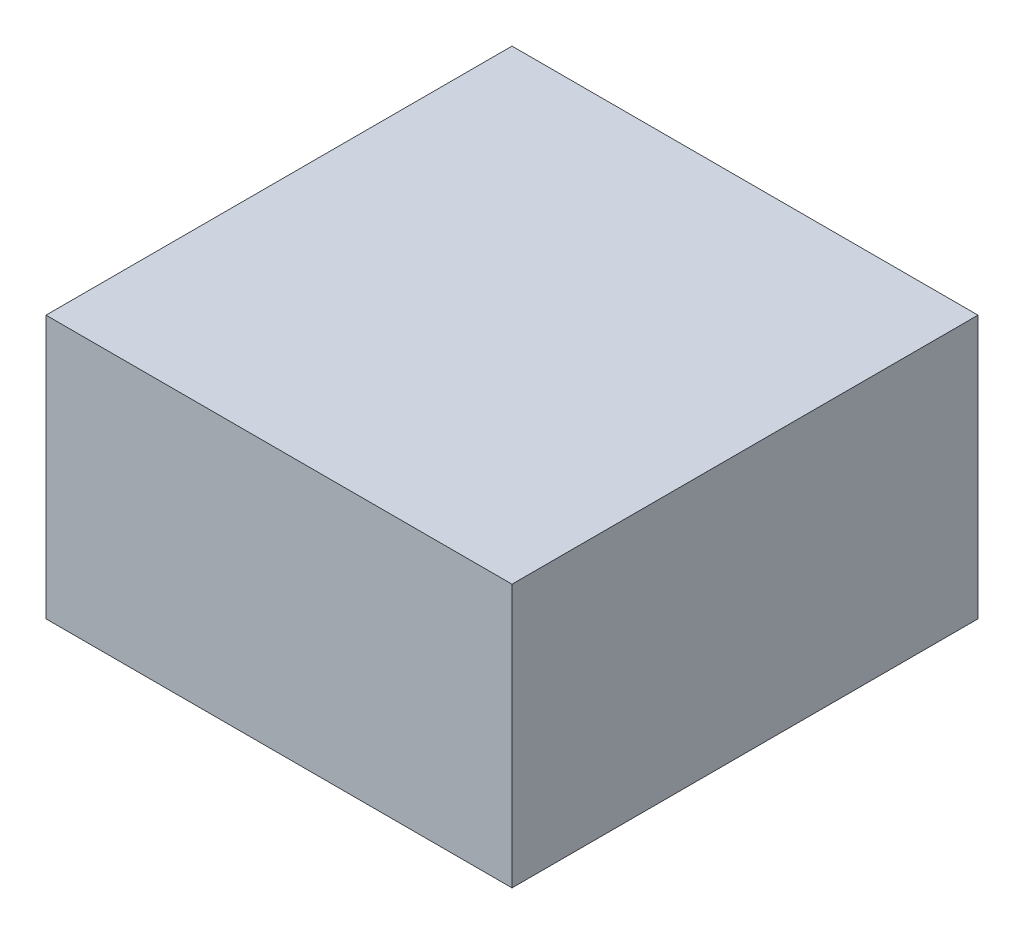
from build123d import *

# Parameters (mm, degrees)
SKETCH1_W           = 45
SKETCH1_H           = 45
BOSS_EXTRUDE1_DEPTH = 25.4


with BuildPart() as part:
    # Sketch1 → Boss-Extrude1 (new body)
    with BuildSketch(Plane(origin=(0, 0, 0), x_dir=(1, 0, 0), z_dir=(0, 1, 0))):
        Rectangle(SKETCH1_W, SKETCH1_H)
    extrude(amount=BOSS_EXTRUDE1_DEPTH)


solid = part.part
